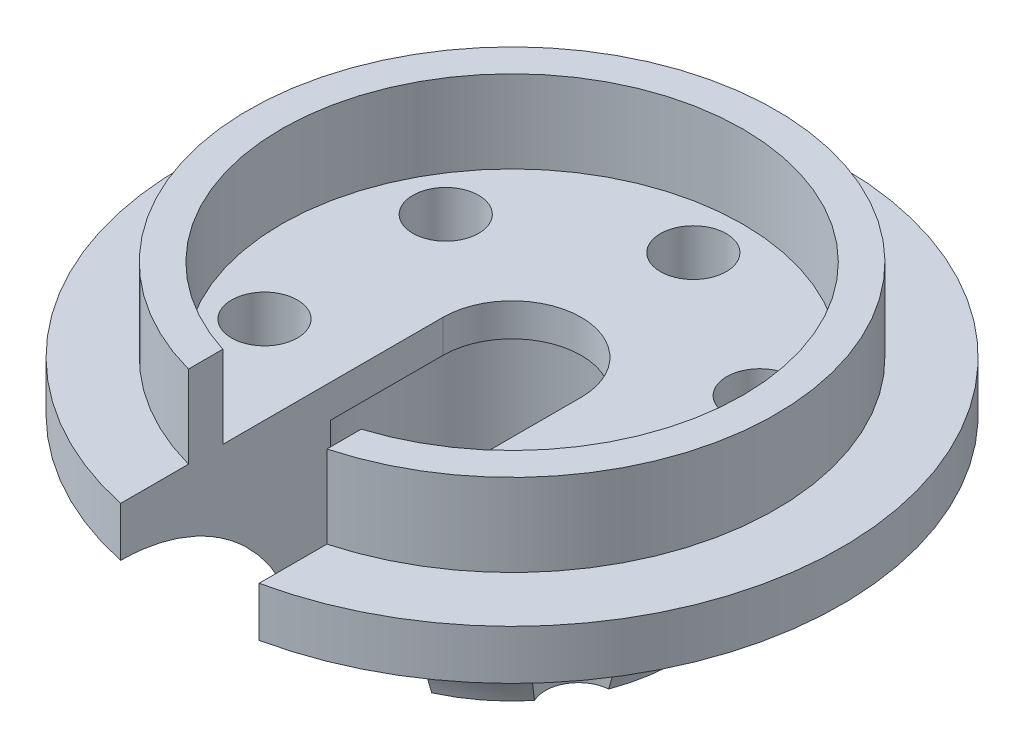
from build123d import *

# Parameters (mm, degrees)
SKETCH2_R          = 7
CUT_EXTRUDE1_DEPTH = 2.5
SKETCH3_R          = 2.1
CUT_EXTRUDE2_DEPTH = 6.5
SKETCH4_R          = 4
CUT_EXTRUDE3_DEPTH = 4.5
CUT_EXTRUDE4_REACH = 22
SKETCH5_W          = 4.2
SKETCH5_H          = 5.5
SKETCH5_H_2        = 3.449205174
SKETCH6_R          = 1
CUT_EXTRUDE5_DEPTH = 6.5000001


with BuildPart() as part:
    # Sketch1 → Revolve1 (revolve)
    with BuildSketch(Plane.XY):
        with BuildLine():
            Line((0, 0), (0, 8))
            Line((0, 8), (-8, 8))
            Line((-8, 8), (-8, 5.5))
            Line((-8, 5.5), (-10, 5.5))
            Line((-10, 5.5), (-10, 4))
            ThreePointArc((-10, 4), (-6.798437881, 2.876952648), (-5, 0))
            Line((-5, 0), (0, 0))
        make_face()
    revolve(axis=Axis((0, 0, 0), (0, 1, 0)))

    # Sketch2 → Cut-Extrude1 (cut)
    with BuildSketch(Plane(origin=(0, 8, 0), x_dir=(1, 0, 0), z_dir=(0, 1, 0))):
        Circle(SKETCH2_R)
    extrude(amount=-CUT_EXTRUDE1_DEPTH, mode=Mode.SUBTRACT)

    # Sketch3 → Cut-Extrude2 (cut, through all)
    with BuildSketch(Plane(origin=(0, 5.5, 0), x_dir=(1, 0, 0), z_dir=(0, 1, 0))):
        Circle(SKETCH3_R)
    extrude(amount=-CUT_EXTRUDE2_DEPTH, mode=Mode.SUBTRACT)

    # Sketch4 → Cut-Extrude3 (cut)
    with BuildSketch(Plane.XZ):
        Circle(SKETCH4_R)
    extrude(amount=-CUT_EXTRUDE3_DEPTH, mode=Mode.SUBTRACT)

    # Sketch5 → Cut-Extrude4 (cut, up to next)
    with BuildSketch(Plane.XY.offset(10), mode=Mode.PRIVATE) as cut_extrude4_sk1:
        with Locations((0, 2.75)):
            Rectangle(SKETCH5_W, SKETCH5_H)
    cut_extrude4_tool1 = extrude(cut_extrude4_sk1.sketch, amount=-CUT_EXTRUDE4_REACH, mode=Mode.PRIVATE) & part.part
    add(cut_extrude4_tool1.solids().sort_by_distance((0, 2.75, 10))[0], mode=Mode.SUBTRACT)
    # Sketch5 → Cut-Extrude4 (cut, up to next)
    with BuildSketch(Plane.XY.offset(10), mode=Mode.PRIVATE) as cut_extrude4_sk2:
        with Locations((0, 7.224602587)):
            Rectangle(SKETCH5_W, SKETCH5_H_2)
    cut_extrude4_tool2 = extrude(cut_extrude4_sk2.sketch, amount=-CUT_EXTRUDE4_REACH, mode=Mode.PRIVATE) & part.part
    add(cut_extrude4_tool2.solids().sort_by_distance((0, 7.224603, 10))[0], mode=Mode.SUBTRACT)

    # Sketch6 → Cut-Extrude5 (cut, through all)
    with BuildSketch(Plane(origin=(0, 5.5, 0), x_dir=(1, 0, 0), z_dir=(0, 1, 0))):
        with Locations((0, 5.5)):
            Circle(SKETCH6_R)
        with Locations((-4.763139721, 2.75)):
            Circle(SKETCH6_R)
        with Locations((-4.763139721, -2.75)):
            Circle(SKETCH6_R)
        with Locations((0, -5.5)):
            Circle(SKETCH6_R)
        with Locations((4.763139721, -2.75)):
            Circle(SKETCH6_R)
        with Locations((4.763139721, 2.75)):
            Circle(SKETCH6_R)
    extrude(amount=-CUT_EXTRUDE5_DEPTH, mode=Mode.SUBTRACT)


solid = part.part
